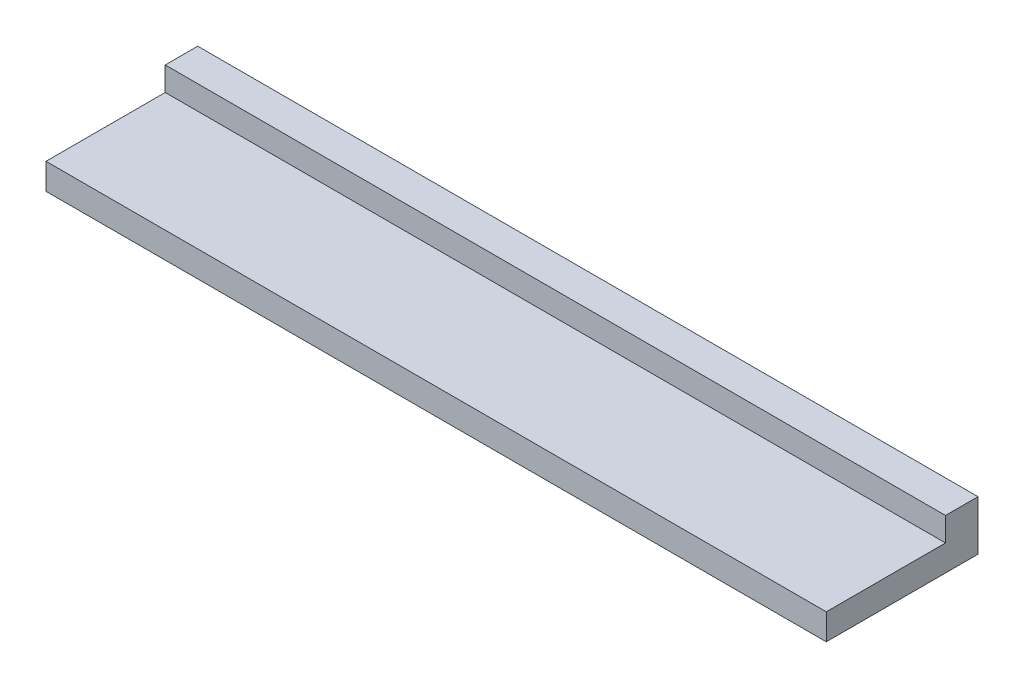
from build123d import *

# Parameters (mm, degrees)
SKETCH_1_W      = 180
SKETCH_1_H      = 35
EXTRUDE_1_DEPTH = 6
SKETCH_2_W      = 180
SKETCH_2_H      = 7.5
EXTRUDE_2_DEPTH = 5.5


with BuildPart() as part:
    # Эскиз1 → Бобышка-Вытянуть1 (new body)
    with BuildSketch(Plane(origin=(0, 0, 0), x_dir=(1, 0, 0), z_dir=(0, 1, 0))):
        Rectangle(SKETCH_1_W, SKETCH_1_H)
    extrude(amount=EXTRUDE_1_DEPTH)

    # Эскиз2 → Бобышка-Вытянуть2 (add)
    with BuildSketch(Plane(origin=(0, 6, 0), x_dir=(1, 0, 0), z_dir=(0, 1, 0))):
        with Locations((0, 13.75)):
            Rectangle(SKETCH_2_W, SKETCH_2_H)
    extrude(amount=EXTRUDE_2_DEPTH)


solid = part.part
